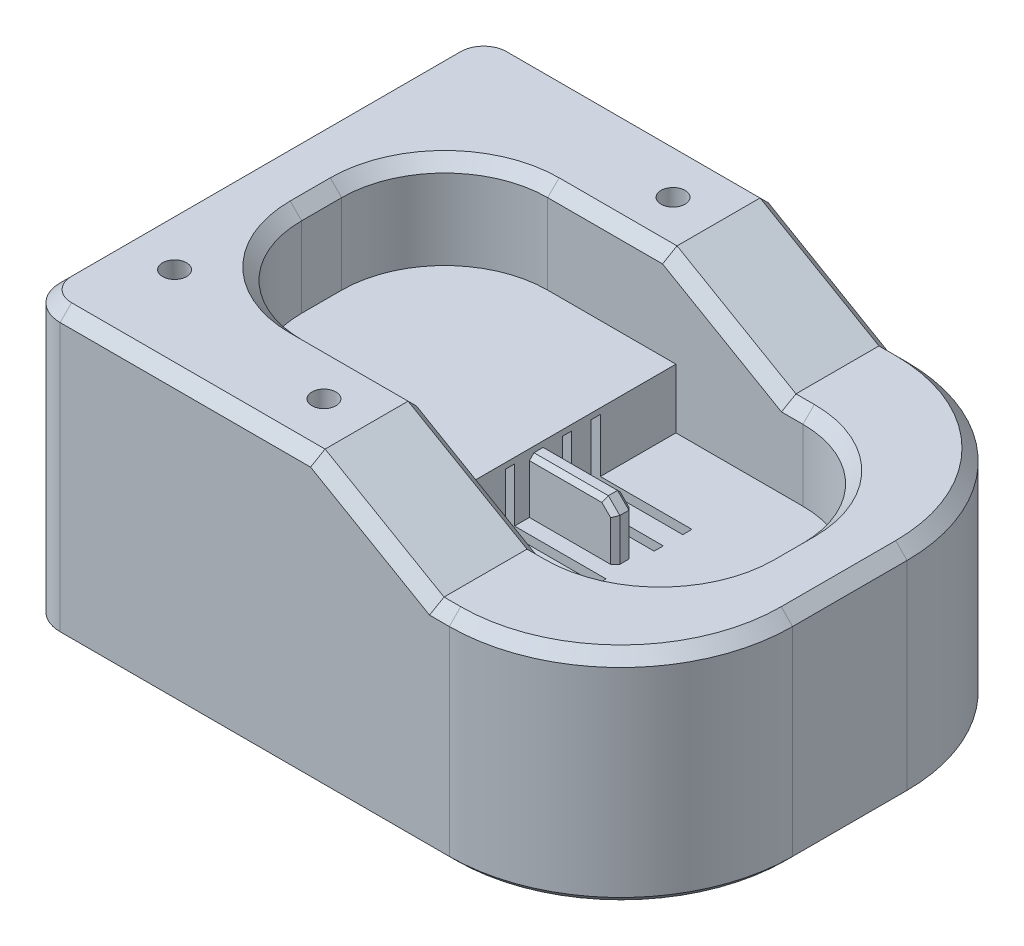
from build123d import *

# Parameters (mm, degrees)
BOSS_EXTRUDE1_DEPTH      = 11.25
CUT_EXTRUDE1_DEPTH       = 8
CUT_EXTRUDE2_DEPTH       = 5.2
SKETCH4_W                = 0.8
SKETCH4_H                = 4.7
SKETCH4_H_2              = 1.8
CUT_EXTRUDE3_DEPTH       = 8
CUT_EXTRUDE3_DEPTH_BACK  = 14
SKETCH4_3_W              = 1.6
SKETCH4_3_H              = 4.7
BOSS_EXTRUDE2_DEPTH      = 7.5
CUT_EXTRUDE4_DEPTH       = 6
SKETCH6_W                = 8
SKETCH6_H                = 4
CUT_EXTRUDE5_DEPTH       = 2.6
SKETCH8_W                = 10
SKETCH8_H                = 9.5
SKETCH8_H_2              = 0.8
SKETCH8_H_3              = 2
CUT_EXTRUDE7_DEPTH       = 6.5
SKETCH9_W                = 12
SKETCH9_H                = 0.8
CUT_EXTRUDE8_DEPTH       = 1.5
SKETCH11_R               = 1.05
CHAMFER1_SIZE            = 1
CHAMFER2_SIZE            = 0.4
SKETCH16_R               = 1.05
SKETCH16_5_R             = 1.05
BOSS_EXTRUDE3_DEPTH      = 2.5
SKETCH19_R               = 1.15
CUT_EXTRUDE10_DEPTH      = 5
SKETCH20_R               = 2.82
SKETCH20_R_2             = 1.15
SKETCH20_W               = 6
SKETCH20_H               = 0.8
BOSS_EXTRUDE4_DEPTH      = 4.2
SKETCH28_W               = 5.85
SKETCH28_H               = 6
CUT_EXTRUDE11_DEPTH      = 21
CUT_EXTRUDE11_DEPTH_BACK = 21
CHAMFER3_SIZE            = 1
CHAMFER4_SIZE            = 0.6


with BuildPart() as part:
    # Sketch1 → Boss-Extrude1 (new body, symmetric)
    with BuildSketch(Plane(origin=(0, 0, 0), x_dir=(1, 0, 0), z_dir=(0, 1, 0))):
        with BuildLine():
            Line((-23, 20), (11, 20))
            ThreePointArc((11, 20), (21.606601718, 15.606601718), (26, 5))
            Line((26, 5), (26, -5))
            ThreePointArc((26, -5), (21.606601718, -15.606601718), (11, -20))
            Line((11, -20), (-23, -20))
            ThreePointArc((-23, -20), (-25.121320344, -19.121320344), (-26, -17))
            Line((-26, -17), (-26, 17))
            ThreePointArc((-26, 17), (-25.121320344, 19.121320344), (-23, 20))
        make_face()
    extrude(amount=BOSS_EXTRUDE1_DEPTH, both=True)

    # Sketch2 → Cut-Extrude1 (cut)
    with BuildSketch(Plane(origin=(0, 11.25, 0), x_dir=(1, 0, 0), z_dir=(0, 1, 0))):
        with BuildLine():
            Line((-11.15, 10.75), (11.15, 10.75))
            ThreePointArc((11.15, 10.75), (17.513961031, 8.113961031), (20.15, 1.75))
            Line((20.15, 1.75), (20.15, -1.75))
            ThreePointArc((20.15, -1.75), (17.513961031, -8.113961031), (11.15, -10.75))
            Line((11.15, -10.75), (-11.15, -10.75))
            ThreePointArc((-11.15, -10.75), (-17.513961031, -8.113961031), (-20.15, -1.75))
            Line((-20.15, -1.75), (-20.15, 1.75))
            ThreePointArc((-20.15, 1.75), (-17.513961031, 8.113961031), (-11.15, 10.75))
        make_face()
    extrude(amount=-CUT_EXTRUDE1_DEPTH, mode=Mode.SUBTRACT)

    # Sketch3 → Cut-Extrude2 (cut)
    with BuildSketch(Plane(origin=(0, 3.25, 0), x_dir=(1, 0, 0), z_dir=(0, 1, 0))):
        with BuildLine():
            Line((11.15, 10.75), (0.05, 10.75))
            Line((0.05, 10.75), (0.05, -10.75))
            Line((0.05, -10.75), (11.15, -10.75))
            ThreePointArc((11.15, -10.75), (17.513961031, -8.113961031), (20.15, -1.75))
            Line((20.15, -1.75), (20.15, 1.75))
            ThreePointArc((20.15, 1.75), (17.513961031, 8.113961031), (11.15, 10.75))
        make_face()
    extrude(amount=-CUT_EXTRUDE2_DEPTH, mode=Mode.SUBTRACT)

    # Sketch4 → Cut-Extrude3 (cut, two sides)
    with BuildSketch(Plane(origin=(0.05, 0, 0), x_dir=(0, 0, -1), z_dir=(1, 0, 0))) as cut_extrude3_sk:
        with Locations((-3.75, 0.4)):
            Rectangle(SKETCH4_W, SKETCH4_H)
        with Locations((1.25, 0.4)):
            Rectangle(SKETCH4_W, SKETCH4_H)
        with Locations((3.75, 0.4)):
            Rectangle(SKETCH4_W, SKETCH4_H)
        with Locations((-3.75, -2.85)):
            Rectangle(SKETCH4_W, SKETCH4_H_2)
        with Locations((1.25, -2.85)):
            Rectangle(SKETCH4_W, SKETCH4_H_2)
        with Locations((3.75, -2.85)):
            Rectangle(SKETCH4_W, SKETCH4_H_2)
    extrude(amount=CUT_EXTRUDE3_DEPTH, mode=Mode.SUBTRACT)
    extrude(cut_extrude3_sk.sketch, amount=-CUT_EXTRUDE3_DEPTH_BACK, mode=Mode.SUBTRACT)

    # Sketch4_3 → Boss-Extrude2 (add)
    with BuildSketch(Plane(origin=(0.05, 0, 0), x_dir=(0, 0, -1), z_dir=(1, 0, 0))):
        with Locations((-1.25, 0.4)):
            Rectangle(SKETCH4_3_W, SKETCH4_3_H)
    extrude(amount=BOSS_EXTRUDE2_DEPTH)

    # Sketch5 → Cut-Extrude4 (cut)
    with BuildSketch(Plane.XZ.offset(11.25)):
        with BuildLine():
            Line((10, -17.7), (-23.4, -17.7))
            ThreePointArc((-23.4, -17.7), (-24.107106781, -17.407106781), (-24.4, -16.7))
            Line((-24.4, -16.7), (-24.4, 16.7))
            ThreePointArc((-24.4, 16.7), (-24.107106781, 17.407106781), (-23.4, 17.7))
            Line((-23.4, 17.7), (10, 17.7))
            ThreePointArc((10, 17.7), (10.707106781, 17.407106781), (11, 16.7))
            Line((11, 16.7), (11, -16.7))
            ThreePointArc((11, -16.7), (10.707106781, -17.407106781), (10, -17.7))
        make_face()
    extrude(amount=-CUT_EXTRUDE4_DEPTH, mode=Mode.SUBTRACT)

    # Sketch6 → Cut-Extrude5 (cut, through all)
    with BuildSketch(Plane(origin=(-24.4, 0, 0), x_dir=(0, 0, -1), z_dir=(1, 0, 0))):
        with Locations((0, -7.25)):
            Rectangle(SKETCH6_W, SKETCH6_H)
    extrude(amount=-CUT_EXTRUDE5_DEPTH, mode=Mode.SUBTRACT)

    # Sketch8 → Cut-Extrude7 (cut)
    with BuildSketch(Plane.XZ.offset(5.25)):
        with Locations((-8.95, -1.4)):
            Rectangle(SKETCH8_W, SKETCH8_H)
        with Locations((-8.95, -1.4)):
            Rectangle(SKETCH8_W, SKETCH8_H)
        with Locations((-8.95, 3.75)):
            Rectangle(SKETCH8_W, SKETCH8_H_2)
        with Locations((-8.95, 5.15)):
            Rectangle(SKETCH8_W, SKETCH8_H_3)
    extrude(amount=-CUT_EXTRUDE7_DEPTH, mode=Mode.SUBTRACT)

    # Sketch9 → Cut-Extrude8 (cut)
    with BuildSketch(Plane(origin=(0, -3.75, 0), x_dir=(1, 0, 0), z_dir=(0, 1, 0))):
        with Locations((2.05, -3.75)):
            Rectangle(SKETCH9_W, SKETCH9_H)
        with Locations((2.05, 1.25)):
            Rectangle(SKETCH9_W, SKETCH9_H)
        with Locations((2.05, 3.75)):
            Rectangle(SKETCH9_W, SKETCH9_H)
    extrude(amount=-CUT_EXTRUDE8_DEPTH, mode=Mode.SUBTRACT)

    # Cut-Sweep13: sweep along a curve in space
    with BuildLine() as cut_sweep13_path:
        Line((-21, 11.25, 12), (-22.4, -8.25, 9.5))
    # Sketch11 → Cut-Sweep13 (sweep, cut)
    with BuildSketch(Plane(origin=(0, 11.25, 0), x_dir=(1, 0, 0), z_dir=(0, 1, 0))):
        with Locations((-21, -12)):
            Circle(SKETCH11_R)
    sweep(path=cut_sweep13_path.line, mode=Mode.SUBTRACT)

    # Chamfer1
    chamfer1_edges = [part.edges().sort_by_distance(p)[0] for p in [
        (7.55, 2.75, 1.25),
    ]]
    chamfer(chamfer1_edges, length=CHAMFER1_SIZE)

    # Chamfer2
    chamfer2_edges = [part.edges().sort_by_distance(p)[0] for p in [
        (3.3, 2.75, 2.05),
        (3.3, 2.75, 0.45),
        (7.55, -0.1, 0.45),
        (7.05, 2.25, 0.45),
        (7.55, -0.1, 2.05),
        (7.05, 2.25, 2.05),
    ]]
    chamfer(chamfer2_edges, length=CHAMFER2_SIZE)

    # Cut-Sweep11: sweep along a path in Sketch23
    with BuildLine(Plane(origin=(4.946896552, 0, 4.397241379), x_dir=(0.664363839, 0, -0.747409319), z_dir=(0.747409319, 0, 0.664363839))) as cut_sweep11_path:
        Line((-14.520502152, 11.25), (-14.520502152, 7.25))
        ThreePointArc((-14.520502152, 7.25), (-9.051114041, -4.650630235), (3.541889716, -8.25))
    # Sketch16 → Cut-Sweep11 (sweep, cut)
    with BuildSketch(Plane(origin=(0, 11.25, 0), x_dir=(1, 0, 0), z_dir=(0, 1, 0))):
        with Locations((-4.7, -15.25)):
            Circle(SKETCH16_R)
    sweep(path=cut_sweep11_path.line, mode=Mode.SUBTRACT)

    # Cut-Sweep12: sweep along a path in Sketch22
    with BuildLine(Plane(origin=(4.946896552, 0, -4.397241379), x_dir=(0.664363839, 0, 0.747409319), z_dir=(-0.747409319, 0, 0.664363839))) as cut_sweep12_path:
        Line((-14.520502152, 11.25), (-14.520502152, 7.25))
        ThreePointArc((-14.520502152, 7.25), (-9.051114041, -4.650630235), (3.541889716, -8.25))
    # Sketch16_5 → Cut-Sweep12 (sweep, cut)
    with BuildSketch(Plane(origin=(0, 11.25, 0), x_dir=(1, 0, 0), z_dir=(0, 1, 0))):
        with Locations((-4.7, 15.25)):
            Circle(SKETCH16_5_R)
    sweep(path=cut_sweep12_path.line, mode=Mode.SUBTRACT)

    # Sketch18 → Boss-Extrude3 (add)
    with BuildSketch(Plane.XZ.offset(11.25)):
        with BuildLine():
            Line((-23, -20), (11, -20))
            ThreePointArc((11, -20), (21.606601718, -15.606601718), (26, -5))
            Line((26, -5), (26, 5))
            ThreePointArc((26, 5), (21.606601718, 15.606601718), (11, 20))
            Line((11, 20), (-23, 20))
            ThreePointArc((-23, 20), (-25.121320344, 19.121320344), (-26, 17))
            Line((-26, 17), (-26, -17))
            ThreePointArc((-26, -17), (-25.121320344, -19.121320344), (-23, -20))
        make_face()
        with BuildLine():
            ThreePointArc((-24.4, 16.7), (-24.107106781, 17.407106781), (-23.4, 17.7))
            Line((-23.4, 17.7), (10, 17.7))
            ThreePointArc((10, 17.7), (10.707106781, 17.407106781), (11, 16.7))
            Line((11, 16.7), (11, -16.7))
            ThreePointArc((11, -16.7), (10.707106781, -17.407106781), (10, -17.7))
            Line((10, -17.7), (-23.4, -17.7))
            ThreePointArc((-23.4, -17.7), (-24.107106781, -17.407106781), (-24.4, -16.7))
            Line((-24.4, -16.7), (-24.4, 16.7))
        make_face(mode=Mode.SUBTRACT)
    extrude(amount=BOSS_EXTRUDE3_DEPTH)

    # Sketch19 → Cut-Extrude10 (cut)
    with BuildSketch(Plane.XZ.offset(5.25)):
        with Locations(Location((-21.2, -14.5, 0), (0, 0, 270))):  # turned: the seam where the file's is
            Circle(SKETCH19_R)
        with Locations(Location((-21.2, 14.5, 0), (0, 0, 270))):  # turned: the seam where the file's is
            Circle(SKETCH19_R)
        with Locations(Location((7.8, 14.5, 0), (0, 0, 270))):  # turned: the seam where the file's is
            Circle(SKETCH19_R)
        with Locations(Location((7.8, -14.5, 0), (0, 0, 270))):  # turned: the seam where the file's is
            Circle(SKETCH19_R)
    extrude(amount=-CUT_EXTRUDE10_DEPTH, mode=Mode.SUBTRACT)

    # Sketch20 → Boss-Extrude4 (add)
    with BuildSketch(Plane.XZ.offset(5.25)):
        with BuildLine():
            Line((-23.4, -17.7), (-18.077116717, -17.7))
            ThreePointArc((-18.077116717, -17.7), (-18.964786765, -17.160480059), (-18.89462543, -16.12408377))
            ThreePointArc((-18.89462543, -16.12408377), (-23.194041123, -16.494041123), (-22.82408377, -12.19462543))
            ThreePointArc((-22.82408377, -12.19462543), (-23.860480059, -12.264786765), (-24.4, -11.377116717))
            Line((-24.4, -11.377116717), (-24.4, -16.7))
            ThreePointArc((-24.4, -16.7), (-24.107106781, -17.407106781), (-23.4, -17.7))
        make_face()
        with Locations((-21.2, -14.5)):
            Circle(SKETCH20_R)
        with Locations(Location((-21.2, -14.5, 0), (0, 0, 270))):  # turned: the seam where the file's is
            Circle(SKETCH20_R_2, mode=Mode.SUBTRACT)
        with BuildLine():
            ThreePointArc((-18.89462543, 16.12408377), (-18.964786765, 17.160480059), (-18.077116717, 17.7))
            Line((-18.077116717, 17.7), (-23.4, 17.7))
            ThreePointArc((-23.4, 17.7), (-24.107106781, 17.407106781), (-24.4, 16.7))
            Line((-24.4, 16.7), (-24.4, 11.377116717))
            ThreePointArc((-24.4, 11.377116717), (-23.860480059, 12.264786765), (-22.82408377, 12.19462543))
            ThreePointArc((-22.82408377, 12.19462543), (-23.194041123, 16.494041123), (-18.89462543, 16.12408377))
        make_face()
        with Locations((-21.2, 14.5)):
            Circle(SKETCH20_R)
        with Locations(Location((-21.2, 14.5, 0), (0, 0, 270))):  # turned: the seam where the file's is
            Circle(SKETCH20_R_2, mode=Mode.SUBTRACT)
        with Locations((7.8, 14.5)):
            Circle(SKETCH20_R)
        with Locations(Location((7.8, 14.5, 0), (0, 0, 270))):  # turned: the seam where the file's is
            Circle(SKETCH20_R_2, mode=Mode.SUBTRACT)
        with BuildLine():
            ThreePointArc((9.42408377, 12.19462543), (10.460480059, 12.264786765), (11, 11.377116717))
            Line((11, 11.377116717), (11, 16.7))
            ThreePointArc((11, 16.7), (10.707106781, 17.407106781), (10, 17.7))
            Line((10, 17.7), (4.677116717, 17.7))
            ThreePointArc((4.677116717, 17.7), (5.564786765, 17.160480059), (5.49462543, 16.12408377))
            ThreePointArc((5.49462543, 16.12408377), (8.651834406, 17.188266755), (10.62, 14.5))
            ThreePointArc((10.62, 14.5), (10.303229537, 13.201446233), (9.42408377, 12.19462543))
        make_face()
        with BuildLine():
            Line((11, -16.7), (11, -11.377116717))
            ThreePointArc((11, -11.377116717), (10.460480059, -12.264786765), (9.42408377, -12.19462543))
            ThreePointArc((9.42408377, -12.19462543), (10.303229537, -13.201446233), (10.62, -14.5))
            ThreePointArc((10.62, -14.5), (8.651834406, -17.188266755), (5.49462543, -16.12408377))
            ThreePointArc((5.49462543, -16.12408377), (5.564786765, -17.160480059), (4.677116717, -17.7))
            Line((4.677116717, -17.7), (10, -17.7))
            ThreePointArc((10, -17.7), (10.707106781, -17.407106781), (11, -16.7))
        make_face()
        with Locations((7.8, -14.5)):
            Circle(SKETCH20_R)
        with Locations(Location((7.8, -14.5, 0), (0, 0, 270))):  # turned: the seam where the file's is
            Circle(SKETCH20_R_2, mode=Mode.SUBTRACT)
        with Locations((8, 0)):
            Rectangle(SKETCH20_W, SKETCH20_H)
    extrude(amount=BOSS_EXTRUDE4_DEPTH)

    # Sketch28 → Cut-Extrude11 (cut, two sides)
    with BuildSketch(Plane.XY) as cut_extrude11_sk:
        Polygon((9.542304845, 5.25), (20.15, 5.25), (20.15, 11.25), (11, 11.25), (-0.85, 11.25), align=None)
        with Locations((23.075, 8.25)):
            Rectangle(SKETCH28_W, SKETCH28_H)
    extrude(amount=CUT_EXTRUDE11_DEPTH, mode=Mode.SUBTRACT)
    extrude(cut_extrude11_sk.sketch, amount=-CUT_EXTRUDE11_DEPTH_BACK, mode=Mode.SUBTRACT)

    # Chamfer3
    chamfer3_edges = [part.edges().sort_by_distance(p)[0] for p in [
        (-25.121320344, 11.25, -19.121320344),
        (-26, 11.25, 0),
        (-25.121320344, 11.25, 19.121320344),
        (-11.925, 11.25, 20),
        (-17.513961031, 11.25, -8.113961031),
        (-20.15, 11.25, 0),
        (-17.513961031, 11.25, 8.113961031),
        (-6, 11.25, 10.75),
        (20.15, 5.25, 0),
        (-6, 11.25, -10.75),
        (4.346152423, 8.25, -10.75),
        (-11.925, 11.25, -20),
        (4.346152423, 8.25, 10.75),
        (4.346152423, 8.25, -20),
        (10.271152423, 5.25, -20),
        (21.606601718, 5.25, -15.606601718),
        (26, 5.25, 0),
        (21.606601718, 5.25, 15.606601718),
        (10.346152423, 5.25, 10.75),
        (17.513961031, 5.25, 8.113961031),
        (17.513961031, 5.25, -8.113961031),
        (10.346152423, 5.25, -10.75),
        (4.346152423, 8.25, 20),
        (10.271152423, 5.25, 20),
    ]]
    chamfer(chamfer3_edges, length=CHAMFER3_SIZE)

    # Chamfer4
    chamfer4_edges = [part.edges().sort_by_distance(p)[0] for p in [
        (-6, -13.75, -20),
        (21.606601718, -13.75, -15.606601718),
        (26, -13.75, 0),
        (21.606601718, -13.75, 15.606601718),
        (-6, -13.75, 20),
        (-25.121320344, -13.75, 19.121320344),
        (-26, -13.75, 0),
        (-25.121320344, -13.75, -19.121320344),
    ]]
    chamfer(chamfer4_edges, length=CHAMFER4_SIZE)


solid = part.part
